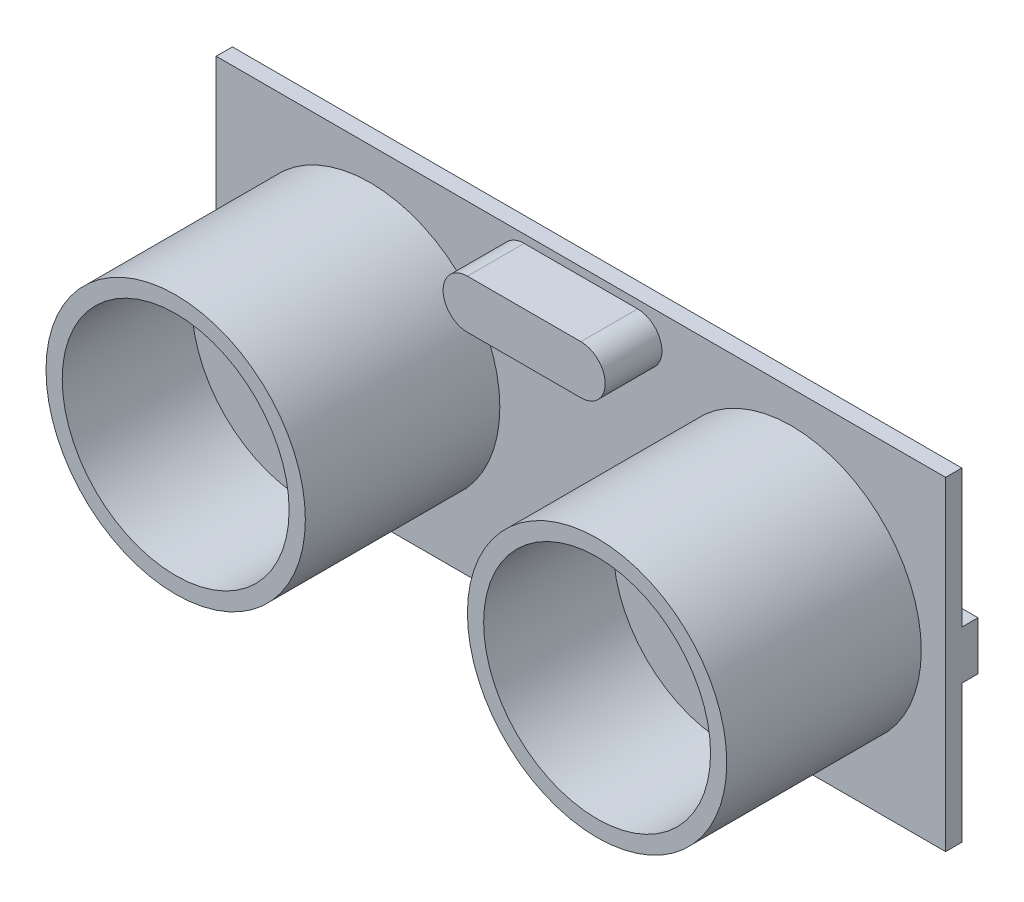
from build123d import *

# Parameters (mm, degrees)
SKETCH1_W           = 45
SKETCH1_H           = 20
BOSS_EXTRUDE1_DEPTH = 1
SKETCH2_R           = 8
BOSS_EXTRUDE2_DEPTH = 12
BOSS_EXTRUDE4_DEPTH = 3.5
SKETCH4_R           = 7
CUT_EXTRUDE1_DEPTH  = 8
SKETCH8_W           = 6
SKETCH8_H           = 3
SKETCH8_W_2         = 3
SKETCH8_H_2         = 6.5
BOSS_EXTRUDE5_DEPTH = 1
SKETCH9_W           = 12.7
SKETCH9_H           = 5
BOSS_EXTRUDE6_DEPTH = 4
SKETCH10_R          = 0.5
BOSS_EXTRUDE7_DEPTH = 8


with BuildPart() as part:
    # Sketch1 → Boss-Extrude1 (new body)
    with BuildSketch(Plane.XY):
        Rectangle(SKETCH1_W, SKETCH1_H)
    extrude(amount=BOSS_EXTRUDE1_DEPTH)

    # Sketch2 → Boss-Extrude2 (add)
    with BuildSketch(Plane.XY.offset(1)):
        with Locations((13, 0)):
            Circle(SKETCH2_R)
        with Locations((-13, 0)):
            Circle(SKETCH2_R)
    extrude(amount=BOSS_EXTRUDE2_DEPTH)

    # Sketch3 → Boss-Extrude4 (add)
    with BuildSketch(Plane.XY.offset(1)):
        with BuildLine():
            Line((-3.5, 6.5), (3.5, 6.5))
            ThreePointArc((3.5, 6.5), (5, 8), (3.5, 9.5))
            Line((3.5, 9.5), (-3.5, 9.5))
            ThreePointArc((-3.5, 9.5), (-5, 8), (-3.5, 6.5))
        make_face()
    extrude(amount=BOSS_EXTRUDE4_DEPTH)

    # Sketch4 → Cut-Extrude1 (cut)
    with BuildSketch(Plane.XY.offset(13)):
        with Locations((-13, 0)):
            Circle(SKETCH4_R)
        with Locations((13, 0)):
            Circle(SKETCH4_R)
    extrude(amount=-CUT_EXTRUDE1_DEPTH, mode=Mode.SUBTRACT)

    # Sketch8 → Boss-Extrude5 (add)
    with BuildSketch(Plane(origin=(0, 0, 0), x_dir=(-1, 0, 0), z_dir=(0, 0, -1))):
        Rectangle(SKETCH8_W, SKETCH8_H)
        with Locations((-19.5, 0)):
            Rectangle(SKETCH8_W, SKETCH8_H)
        with Locations((18.449397774, 0)):
            Rectangle(SKETCH8_W_2, SKETCH8_H_2)
    extrude(amount=BOSS_EXTRUDE5_DEPTH)

    # Sketch9 → Boss-Extrude6 (add)
    with BuildSketch(Plane(origin=(0, 0, 0), x_dir=(-1, 0, 0), z_dir=(0, 0, -1))):
        with Locations((0, -7.5)):
            Rectangle(SKETCH9_W, SKETCH9_H)
    extrude(amount=BOSS_EXTRUDE6_DEPTH)

    # Sketch10 → Boss-Extrude7 (add)
    with BuildSketch(Plane.XZ.offset(10)):
        with Locations((-3.85, -2.098004041)):
            Circle(SKETCH10_R)
        with Locations((-1.31, -2.098004041)):
            Circle(SKETCH10_R)
        with Locations((1.23, -2.098004041)):
            Circle(SKETCH10_R)
        with Locations((3.77, -2.098004041)):
            Circle(SKETCH10_R)
    extrude(amount=BOSS_EXTRUDE7_DEPTH)


solid = part.part
